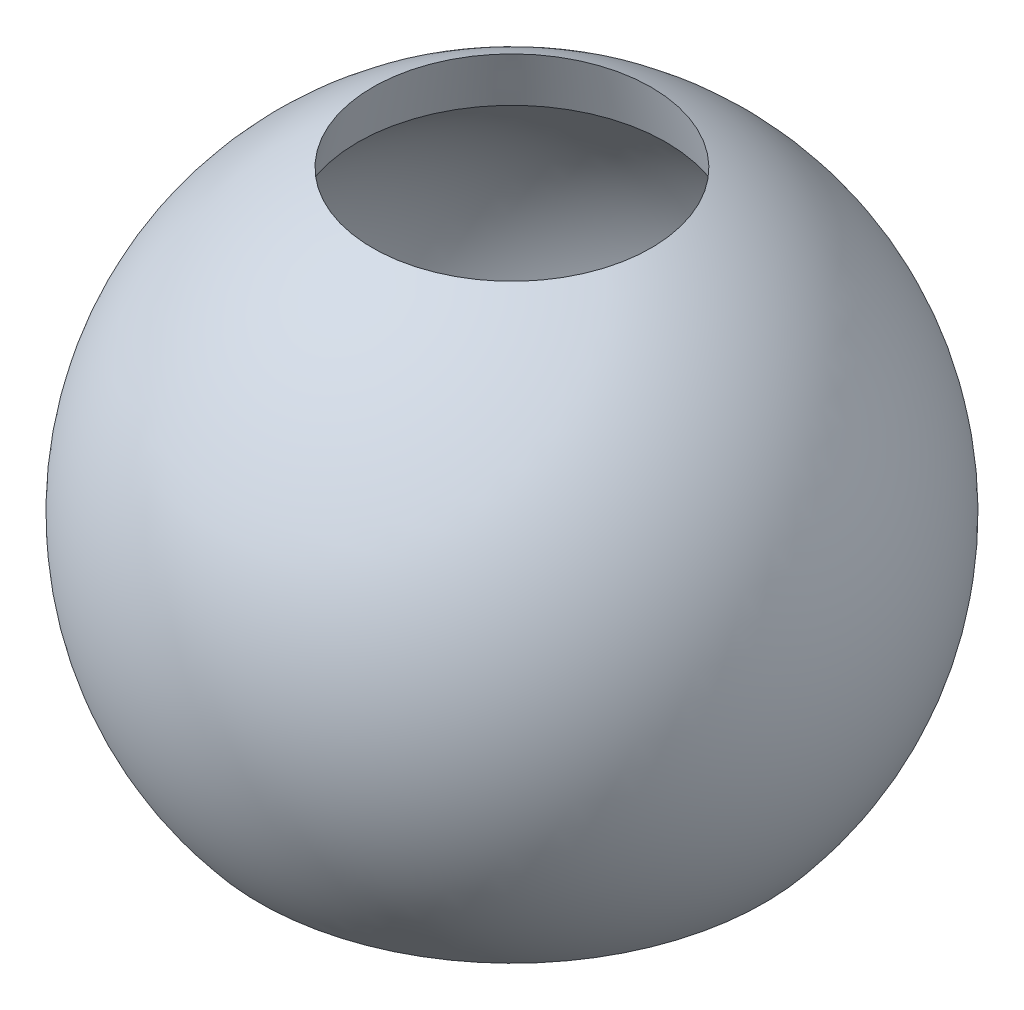
from build123d import *


with BuildPart() as part:
    # Sketch1 → Revolve1 (revolve)
    with BuildSketch(Plane(origin=(0, 0, 0), x_dir=(0, 0, -1), z_dir=(1, 0, 0)), mode=Mode.PRIVATE) as revolve1_sk:
        with BuildLine():
            Line((-5.607317526, 8.875693444), (-5.071419141, 10.875693444))
            ThreePointArc((-5.071419141, 10.875693444), (-11.715552085, 2.597275367), (-9.192533317, -7.713451316))
            Line((-9.192533317, -7.713451316), (-7.121980957, -7.713451316))
            ThreePointArc((-7.121980957, -7.713451316), (-10.455079671, 0.954595736), (-5.607317526, 8.875693444))
        make_face()
    revolve(revolve1_sk.sketch.rotate(Axis((0, 0, 0), (0, 1, 0)), 180), axis=Axis((0, 0, 0), (0, 1, 0)))  # turned: the seam where the file's is


solid = part.part
